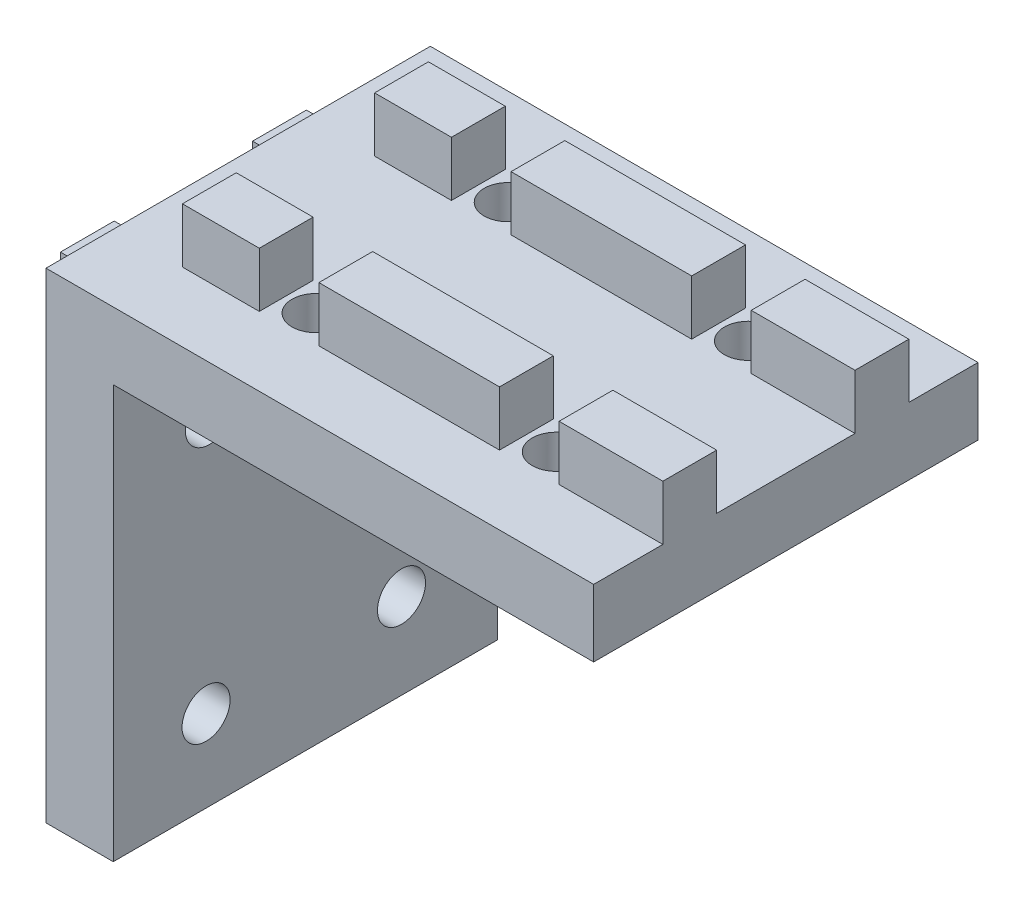
from build123d import *

# Parameters (mm, degrees)
CROQUIS1_W              = 50
CROQUIS1_H              = 40
SALIENTE_EXTRUIR1_DEPTH = 7
CROQUIS3_W              = 5.6
CROQUIS3_H              = 5.7
SALIENTE_EXTRUIR3_DEPTH = 50
CROQUIS9_W              = 40
CROQUIS9_H              = 50
SALIENTE_EXTRUIR8_DEPTH = 7
CROQUIS10_W             = 5.7
CROQUIS10_H             = 5.6
SALIENTE_EXTRUIR9_DEPTH = 45
CROQUIS18_W             = 40
CROQUIS18_H             = 6.2
CORTAR_EXTRUIR4_DEPTH   = 5.7
CROQUIS19_W             = 6.2
CROQUIS19_H             = 40
CORTAR_EXTRUIR5_DEPTH   = 5.7
CROQUIS20_R             = 2.5
CORTAR_EXTRUIR6_DEPTH   = 7
CROQUIS21_R             = 2.5
CORTAR_EXTRUIR7_DEPTH   = 7


with BuildPart() as part:
    # Croquis1 → Saliente-Extruir1 (new body)
    with BuildSketch(Plane(origin=(0, 0, 0), x_dir=(1, 0, 0), z_dir=(0, 1, 0))):
        Rectangle(CROQUIS1_W, CROQUIS1_H)
    extrude(amount=SALIENTE_EXTRUIR1_DEPTH)

    # Croquis3 → Saliente-Extruir3 (add)
    with BuildSketch(Plane.ZY.offset(25)):
        with Locations((10, 9.85)):
            Rectangle(CROQUIS3_W, CROQUIS3_H)
        with Locations((-10, 9.85)):
            Rectangle(CROQUIS3_W, CROQUIS3_H)
    extrude(amount=-SALIENTE_EXTRUIR3_DEPTH)

    # Croquis9 → Saliente-Extruir8 (add)
    with BuildSketch(Plane.ZY.offset(25)):
        with Locations((0, -18)):
            Rectangle(CROQUIS9_W, CROQUIS9_H)
    extrude(amount=SALIENTE_EXTRUIR8_DEPTH)

    # Croquis10 → Saliente-Extruir9 (add)
    with BuildSketch(Plane.XZ.offset(43)):
        with Locations((-34.85, 10)):
            Rectangle(CROQUIS10_W, CROQUIS10_H)
        with Locations((-34.85, -10)):
            Rectangle(CROQUIS10_W, CROQUIS10_H)
    extrude(amount=-SALIENTE_EXTRUIR9_DEPTH)

    # Croquis18 → Cortar-Extruir4 (cut)
    with BuildSketch(Plane.ZY.offset(37.7)):
        with Locations((0, -34.1)):
            Rectangle(CROQUIS18_W, CROQUIS18_H)
        with Locations((0, -7.9)):
            Rectangle(CROQUIS18_W, CROQUIS18_H)
    extrude(amount=-CORTAR_EXTRUIR4_DEPTH, mode=Mode.SUBTRACT)

    # Croquis19 → Cortar-Extruir5 (cut)
    with BuildSketch(Plane(origin=(0, 12.7, 0), x_dir=(1, 0, 0), z_dir=(0, 1, 0))):
        with Locations((-13.9, 0)):
            Rectangle(CROQUIS19_W, CROQUIS19_H)
        with Locations((11.1, 0)):
            Rectangle(CROQUIS19_W, CROQUIS19_H)
    extrude(amount=-CORTAR_EXTRUIR5_DEPTH, mode=Mode.SUBTRACT)

    # Croquis20 → Cortar-Extruir6 (cut)
    with BuildSketch(Plane(origin=(0, 7, 0), x_dir=(1, 0, 0), z_dir=(0, 1, 0))):
        with Locations((-13.9, 10)):
            Circle(CROQUIS20_R)
        with Locations((11.1, 10)):
            Circle(CROQUIS20_R)
        with Locations((11.1, -10)):
            Circle(CROQUIS20_R)
        with Locations((-13.9, -10)):
            Circle(CROQUIS20_R)
    extrude(amount=-CORTAR_EXTRUIR6_DEPTH, mode=Mode.SUBTRACT)

    # Croquis21 → Cortar-Extruir7 (cut)
    with BuildSketch(Plane.ZY.offset(32)):
        with Locations((-10, -7.9)):
            Circle(CROQUIS21_R)
        with Locations((10, -7.9)):
            Circle(CROQUIS21_R)
        with Locations((10.339424261, -34.475791146)):
            Circle(CROQUIS21_R)
        with Locations((-10, -34.1)):
            Circle(CROQUIS21_R)
    extrude(amount=-CORTAR_EXTRUIR7_DEPTH, mode=Mode.SUBTRACT)


solid = part.part
